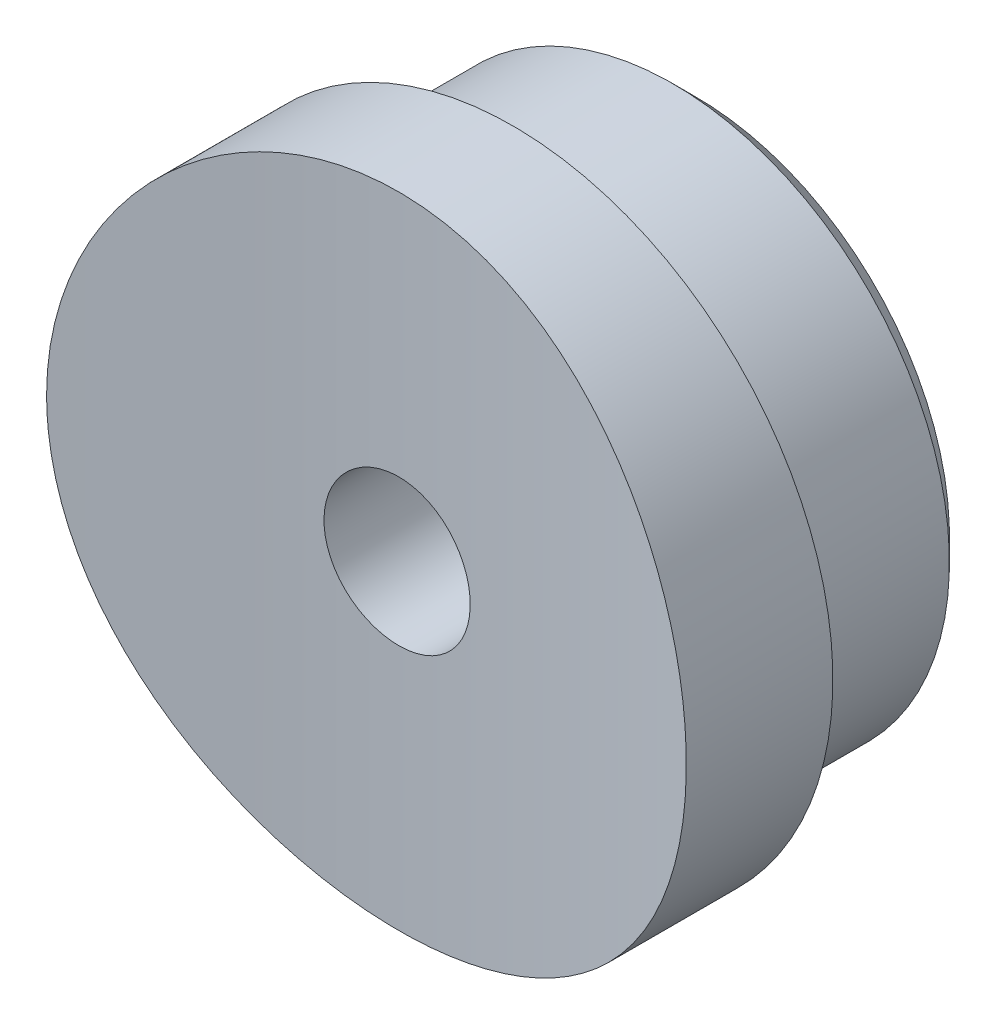
from build123d import *

# Parameters (mm, degrees)
EXTRUDE_1_DEPTH     = 14
CUT_EXTRUDE_3_DEPTH = 14
SKETCH_3_R          = 6.05
EXTRUDE_2_DEPTH     = 4
CHAMFER_1_SIZE      = 0.5
SKETCH_4_R          = 1.6
CUT_EXTRUDE_4_DEPTH = 8.207143701


with BuildPart() as part:
    # Эскиз1 → Бобышка-Вытянуть1 (new body)
    with BuildSketch(Plane(origin=(0, 0, 0), x_dir=(1, 0, 0), z_dir=(0, 1, 0))):
        with BuildLine():
            Line((7, 2.5), (-7, 2.5))
            Line((-7, 2.5), (-7, -0.707143601))
            ThreePointArc((-7, -0.707143601), (0, 0), (7, -0.707143601))
            Line((7, -0.707143601), (7, 2.5))
        make_face()
    extrude(amount=EXTRUDE_1_DEPTH)

    # Эскиз2 → Вырез-Вытянуть3 (cut)
    with BuildSketch(Plane(origin=(0, 0, -2.5), x_dir=(-1, 0, 0), z_dir=(0, 0, -1))):
        with BuildLine():
            ThreePointArc((0, 0), (-4.949747468, 2.050252532), (-7, 7))
            Line((-7, 7), (-7, 0))
            Line((-7, 0), (0, 0))
        make_face()
        with BuildLine():
            Line((0, 14), (-7, 14))
            Line((-7, 14), (-7, 7))
            ThreePointArc((-7, 7), (-4.949747468, 11.949747468), (0, 14))
        make_face()
        with BuildLine():
            Line((7, 14), (0, 14))
            ThreePointArc((0, 14), (4.949747468, 11.949747468), (7, 7))
            Line((7, 7), (7, 14))
        make_face()
        with BuildLine():
            Line((7, 0), (7, 7))
            ThreePointArc((7, 7), (4.949747468, 2.050252532), (0, 0))
            Line((0, 0), (7, 0))
        make_face()
    extrude(amount=-CUT_EXTRUDE_3_DEPTH, mode=Mode.SUBTRACT)

    # Эскиз3 → Бобышка-Вытянуть2 (add)
    with BuildSketch(Plane(origin=(0, 0, -2.5), x_dir=(-1, 0, 0), z_dir=(0, 0, -1))):
        with Locations((0, 7)):
            Circle(SKETCH_3_R)
    extrude(amount=EXTRUDE_2_DEPTH)

    # Фаска1
    chamfer_1_edges = [part.edges().sort_by_distance(p)[0] for p in [
        (6.05, 7, -6.5),
    ]]
    chamfer(chamfer_1_edges, length=CHAMFER_1_SIZE)

    # Эскиз4 → Вырез-Вытянуть4 (cut, through all)
    with BuildSketch(Plane(origin=(0, 0, -6.5), x_dir=(-1, 0, 0), z_dir=(0, 0, -1))):
        with Locations((0, 7)):
            Circle(SKETCH_4_R)
    extrude(amount=-CUT_EXTRUDE_4_DEPTH, mode=Mode.SUBTRACT)


solid = part.part
